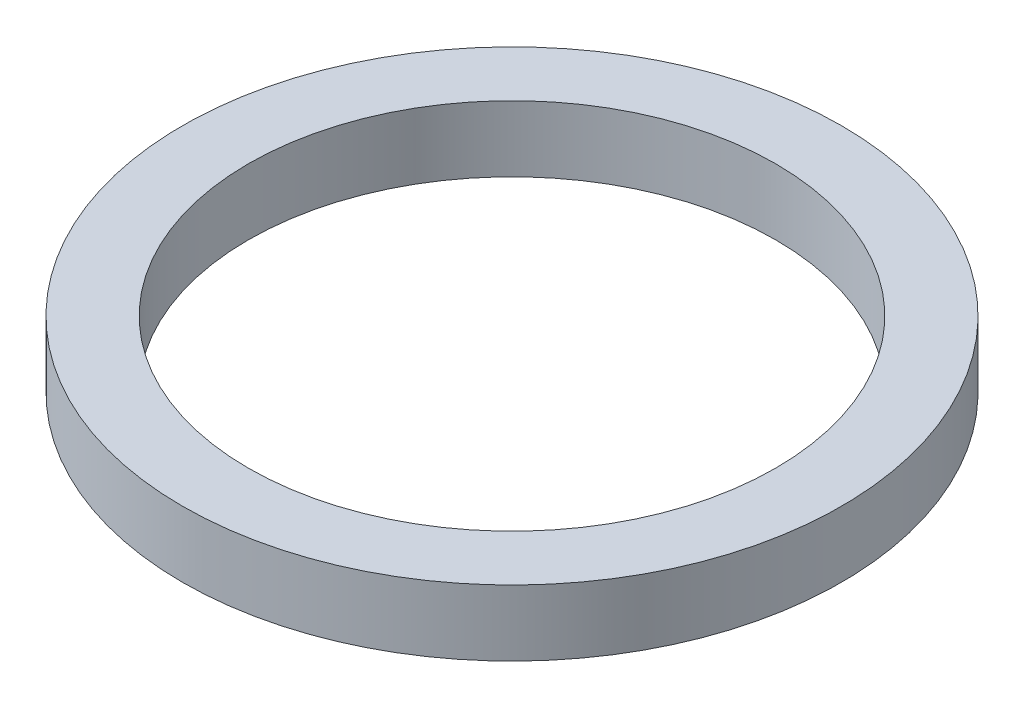
from build123d import *

# Parameters (mm, degrees)
SKETCH1_R           = 15.875
SKETCH1_R_2         = 12.7
BOSS_EXTRUDE1_DEPTH = 3.175


with BuildPart() as part:
    # Sketch1 → Boss-Extrude1 (new body)
    with BuildSketch(Plane(origin=(0, 0, 0), x_dir=(1, 0, 0), z_dir=(0, 1, 0))):
        Circle(SKETCH1_R)
        Circle(SKETCH1_R_2, mode=Mode.SUBTRACT)
    extrude(amount=BOSS_EXTRUDE1_DEPTH)


solid = part.part
